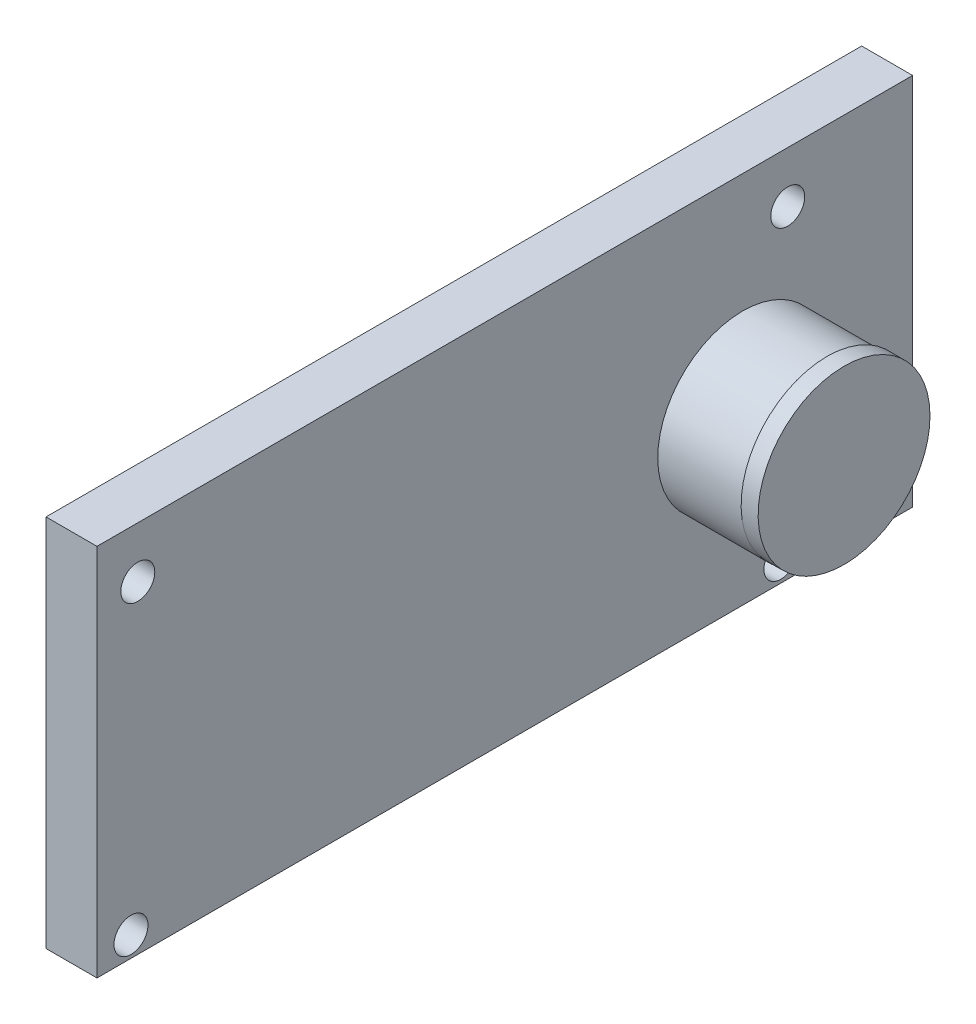
from build123d import *

# Parameters (mm, degrees)
SKETCH1_W           = 48
SKETCH1_H           = 22
SKETCH1_R           = 5
SKETCH1_R_2         = 1
BOSS_EXTRUDE1_DEPTH = 3
SKETCH1_2_R         = 5
BOSS_EXTRUDE2_DEPTH = 8
SKETCH2_W           = 2.104353458
SKETCH2_H           = 1.008785287
SKETCH2_W_2         = 1.832797116
SKETCH2_W_3         = 2.088179476
SKETCH2_W_4         = 0.74441479
SKETCH2_H_2         = 2.033036387
SKETCH2_W_5         = 0.836105694
SKETCH2_W_6         = 1.094706322
BOSS_EXTRUDE3_DEPTH = 0.5
SKETCH2_3_W         = 4.22759305
SKETCH2_3_H         = 1.274477447
SKETCH2_3_W_2       = 3.360802222
SKETCH2_3_H_2       = 1.472211858
SKETCH2_3_W_3       = 1.045429968
SKETCH2_3_H_3       = 1.557369002
SKETCH2_3_W_4       = 1.219219908
SKETCH2_3_H_4       = 2.19777591
SKETCH2_3_W_5       = 1.132324938
SKETCH2_3_H_5       = 1.302990818
BOSS_EXTRUDE4_DEPTH = 0.8
SKETCH2_4_W         = 10.139826511
SKETCH2_4_H         = 3.693874046
BOSS_EXTRUDE5_DEPTH = 1.2
SKETCH2_5_R         = 1.47373415
SKETCH2_5_R_2       = 1.302990818
BOSS_EXTRUDE6_DEPTH = 1.5
SKETCH4_R           = 5.057320887
BOSS_EXTRUDE7_DEPTH = 1


with BuildPart() as part:
    # Sketch1 → Boss-Extrude1 (new body)
    with BuildSketch(Plane(origin=(0, 0, 0), x_dir=(0, 0, -1), z_dir=(1, 0, 0))):
        with Locations((24, 11)):
            Rectangle(SKETCH1_W, SKETCH1_H)
        with Locations((38, 9.99550505)):
            Circle(SKETCH1_R, mode=Mode.SUBTRACT)
        with Locations((40.65, 18.99550505)):
            Circle(SKETCH1_R_2, mode=Mode.SUBTRACT)
        with Locations((2.4, 18.99550505)):
            Circle(SKETCH1_R_2, mode=Mode.SUBTRACT)
        with Locations((2, 1.2)):
            Circle(SKETCH1_R_2, mode=Mode.SUBTRACT)
        with Locations((40.25, 1.2)):
            Circle(SKETCH1_R_2, mode=Mode.SUBTRACT)
    extrude(amount=BOSS_EXTRUDE1_DEPTH)

    # Sketch1_2 → Boss-Extrude2 (add)
    with BuildSketch(Plane(origin=(0, 0, 0), x_dir=(0, 0, -1), z_dir=(1, 0, 0))):
        with Locations((38, 9.99550505)):
            Circle(SKETCH1_2_R)
    extrude(amount=BOSS_EXTRUDE2_DEPTH)

    # Sketch2 → Boss-Extrude3 (add)
    with BuildSketch(Plane.ZY):
        with Locations((-16.200734104, 17.368839016)):
            Rectangle(SKETCH2_W, SKETCH2_H)
        with Locations((-12.333531989, 17.368839016)):
            Rectangle(SKETCH2_W_2, SKETCH2_H)
        with Locations((-7.896046505, 17.368839016)):
            Rectangle(SKETCH2_W_3, SKETCH2_H)
        with Locations((-27.104604618, 3.695463372)):
            Rectangle(SKETCH2_W_4, SKETCH2_H_2)
        with Locations((-29.462717027, 3.695463372)):
            Rectangle(SKETCH2_W_5, SKETCH2_H_2)
        with Locations((-32.481789363, 3.695463372)):
            Rectangle(SKETCH2_W_6, SKETCH2_H_2)
    extrude(amount=BOSS_EXTRUDE3_DEPTH)

    # Sketch2_3 → Boss-Extrude4 (add)
    with BuildSketch(Plane.ZY):
        with Locations((-13.530929956, 8.546365696)):
            Rectangle(SKETCH2_3_W, SKETCH2_3_H)
        with Locations((-4.603155303, 7.810259766)):
            Rectangle(SKETCH2_3_W_2, SKETCH2_3_H_2)
        with Locations((-46.592324849, 9.96228892)):
            Rectangle(SKETCH2_3_W_3, SKETCH2_3_H_3)
        with Locations((-45.982714895, 4.794351326)):
            Rectangle(SKETCH2_3_W_4, SKETCH2_3_H_4)
        with Locations((-46.548877364, 2.027449769)):
            Rectangle(SKETCH2_3_W_5, SKETCH2_3_H_5)
    extrude(amount=BOSS_EXTRUDE4_DEPTH)

    # Sketch2_4 → Boss-Extrude5 (add)
    with BuildSketch(Plane.ZY):
        with Locations((-26.864522947, 12.587910444)):
            Rectangle(SKETCH2_4_W, SKETCH2_4_H)
    extrude(amount=BOSS_EXTRUDE5_DEPTH)

    # Sketch2_5 → Boss-Extrude6 (add)
    with BuildSketch(Plane.ZY):
        with Locations((-15.644726481, 4.711981565)):
            Circle(SKETCH2_5_R)
        with Locations((-6.851956767, 2.678945178)):
            Circle(SKETCH2_5_R_2)
    extrude(amount=BOSS_EXTRUDE6_DEPTH)

    # Sketch4 → Boss-Extrude7 (add)
    with BuildSketch(Plane(origin=(8, 0, 0), x_dir=(0, 0, -1), z_dir=(1, 0, 0))):
        with Locations((37.964303181, 10.142557879)):
            Circle(SKETCH4_R)
    extrude(amount=BOSS_EXTRUDE7_DEPTH)


solid = part.part
